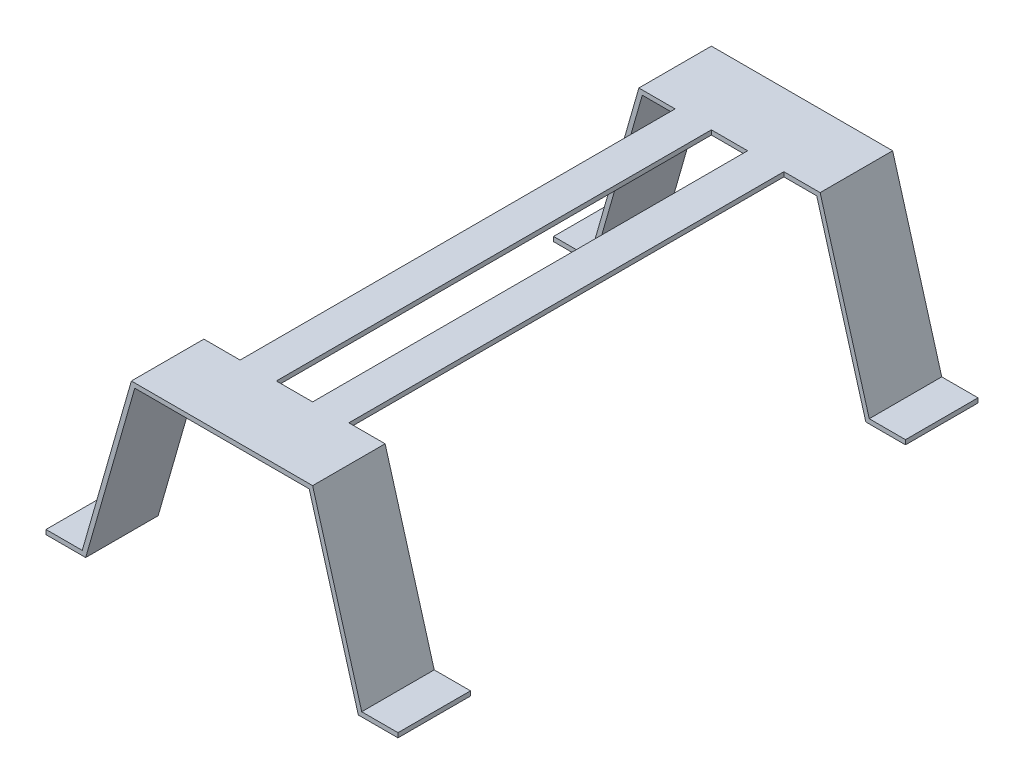
from build123d import *

# Parameters (mm, degrees)
BOSS_EXTRUDE1_DEPTH = 50.8
SKETCH2_W           = 25.4
SKETCH2_H           = 3.175
BOSS_EXTRUDE2_DEPTH = 304.8
BOSS_EXTRUDE4_DEPTH = 50.8


with BuildPart() as part:
    # Sketch1 → Boss-Extrude1 (new body)
    with BuildSketch(Plane.XY):
        Polygon((-29.786832061, -3.837169287), (-4.386832061, -3.837169287), (30.02261423, 116.162830713), (157.02261423, 116.162830713), (191.432060521, -3.837169287), (216.832060521, -3.837169287), (216.832060521, -7.012169287), (189.039526412, -7.012169287), (154.630080121, 112.987830713), (32.415148339, 112.987830713), (-1.994297952, -7.012169287), (-29.786832061, -7.012169287), align=None)
    extrude(amount=BOSS_EXTRUDE1_DEPTH)

    # Sketch2 → Boss-Extrude2 (add)
    with BuildSketch(Plane.XY.offset(50.8)):
        with Locations((68.12261423, 114.575330713)):
            Rectangle(SKETCH2_W, SKETCH2_H)
        with Locations((118.92261423, 114.575330713)):
            Rectangle(SKETCH2_W, SKETCH2_H)
    extrude(amount=BOSS_EXTRUDE2_DEPTH)

    # Sketch4 → Boss-Extrude4 (add)
    with BuildSketch(Plane.XY.offset(355.6)):
        Polygon((30.02261423, 116.162830713), (157.02261423, 116.162830713), (191.432060521, -3.837169287), (216.832060521, -3.837169287), (216.832060521, -7.012169287), (189.039526412, -7.012169287), (154.630080121, 112.987830713), (32.415148339, 112.987830713), (-1.994297952, -7.012169287), (-29.786832061, -7.012169287), (-29.786832061, -3.837169287), (-4.386832061, -3.837169287), align=None)
    extrude(amount=BOSS_EXTRUDE4_DEPTH)


solid = part.part
